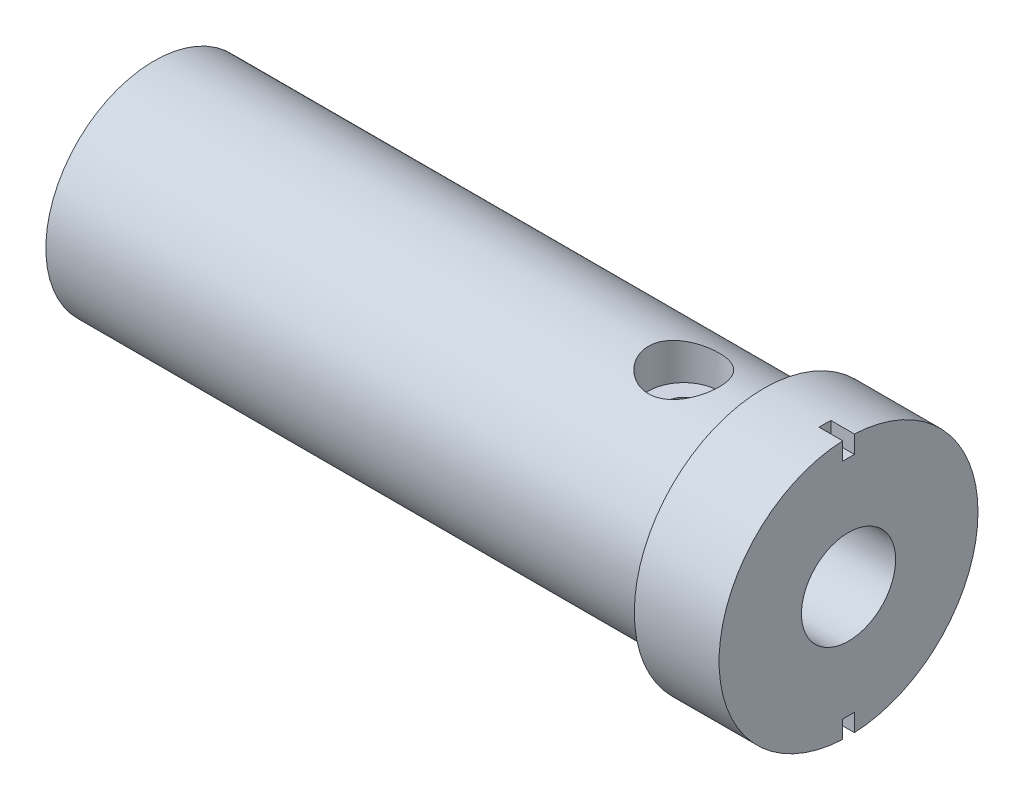
from build123d import *

# Parameters (mm, degrees)
SKETCH2_R          = 4
CUT_EXTRUDE1_DEPTH = 20
SKETCH3_R          = 1.475
CUT_EXTRUDE3_DEPTH = 62.650709647
CUT_EXTRUDE4_START = 2.8
SKETCH3_4_R        = 3
SKETCH3_4_R_2      = 1.475
CUT_EXTRUDE4_DEPTH = 59.850709743
CUT_EXTRUDE5_START = -2
CUT_EXTRUDE5_DEPTH = 2


with BuildPart() as part:
    # Sketch1 → Revolve1 (revolve)
    with BuildSketch(Plane(origin=(0, 0, 0), x_dir=(1, 0, 0), z_dir=(0, 1, 0))):
        Polygon((0, 0), (0, 11), (-7.2, 11), (-7.2, 9.2), (-59, 9.2), (-59, 0), align=None)
    revolve(axis=Axis((0, 0, 0), (-1, 0, 0)))

    # Sketch2 → Cut-Extrude1 (cut)
    with BuildSketch(Plane(origin=(0, 0, 0), x_dir=(0, 0, -1), z_dir=(1, 0, 0))):
        Circle(SKETCH2_R)
    extrude(amount=-CUT_EXTRUDE1_DEPTH, mode=Mode.SUBTRACT)

    # Sketch3 → Cut-Extrude3 (cut, through all)
    with BuildSketch(Plane(origin=(0, 3.1, 0), x_dir=(-1, 0, 0), z_dir=(0, 1, 0))):
        with Locations((14, 0)):
            Circle(SKETCH3_R)
    extrude(amount=CUT_EXTRUDE3_DEPTH, mode=Mode.SUBTRACT)

    # Sketch3_4 → Cut-Extrude4 (cut, through all)
    with BuildSketch(Plane(origin=(0, 3.1, 0), x_dir=(-1, 0, 0), z_dir=(0, 1, 0)).offset(CUT_EXTRUDE4_START)):
        with Locations((14, 0)):
            Circle(SKETCH3_4_R)
        with Locations((14, 0)):
            Circle(SKETCH3_4_R_2, mode=Mode.SUBTRACT)
    extrude(amount=CUT_EXTRUDE4_DEPTH, mode=Mode.SUBTRACT)

    # Sketch2_6 → Cut-Extrude5 (cut)
    with BuildSketch(Plane(origin=(0, 0, 0), x_dir=(0, 0, -1), z_dir=(1, 0, 0)).offset(CUT_EXTRUDE5_START)):
        with BuildLine():
            Line((0.5, 9.488630488), (0.5, 10.988630488))
            ThreePointArc((0.5, 10.988630488), (0, 11), (-0.5, 10.988630488))
            Line((-0.5, 10.988630488), (-0.5, 9.488630488))
            Line((-0.5, 9.488630488), (0.5, 9.488630488))
        make_face()
        with BuildLine():
            ThreePointArc((-0.5, -10.988630488), (0, -11), (0.5, -10.988630488))
            Line((0.5, -10.988630488), (0.5, -9.488630488))
            Line((0.5, -9.488630488), (-0.5, -9.488630488))
            Line((-0.5, -9.488630488), (-0.5, -10.988630488))
        make_face()
    extrude(amount=CUT_EXTRUDE5_DEPTH, mode=Mode.SUBTRACT)


solid = part.part
